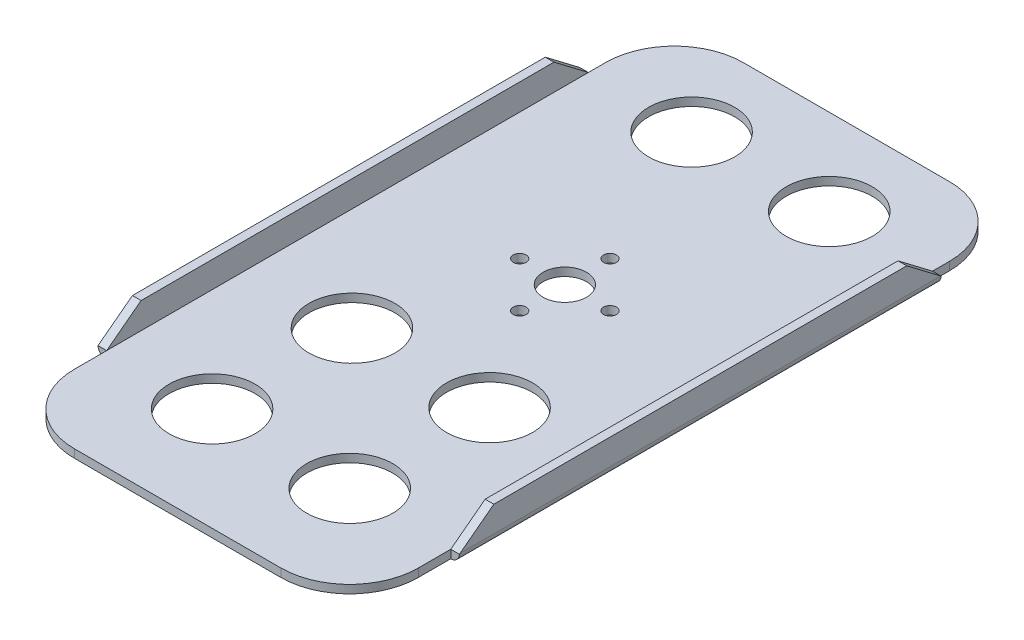
from build123d import *

# Parameters (mm, degrees)
SKETCH1_R               = 7.9375
SKETCH1_R_2             = 4.0005
SKETCH1_R_3             = 1.1938
EXTRUDE1_DEPTH          = 1.524
EXTRUDE2_DEPTH          = 6.35
CUT_EXTRUDE1_DEPTH      = 34.3502
CUT_EXTRUDE1_DEPTH_BACK = 34.3502
FILLET1_R               = 1.5875


with BuildPart() as part:
    # Sketch1 → Extrude1 (new body)
    with BuildSketch(Plane(origin=(0, 0, 0), x_dir=(1, 0, 0), z_dir=(0, 1, 0))):
        with BuildLine():
            Line((-31.75, -3.2004), (-31.75, -58.7756))
            ThreePointArc((-31.75, -58.7756), (-28.030256121, -67.755856121), (-19.05, -71.4756))
            Line((-19.05, -71.4756), (19.05, -71.4756))
            ThreePointArc((19.05, -71.4756), (28.030256121, -67.755856121), (31.75, -58.7756))
            Line((31.75, -58.7756), (31.75, -3.2004))
            Line((31.75, -3.2004), (31.75, 39.2684))
            ThreePointArc((31.75, 39.2684), (28.030256121, 48.248656121), (19.05, 51.9684))
            Line((19.05, 51.9684), (12.7, 51.9684))
            Line((12.7, 51.9684), (-12.7, 51.9684))
            Line((-12.7, 51.9684), (-19.05, 51.9684))
            ThreePointArc((-19.05, 51.9684), (-28.030256121, 48.248656121), (-31.75, 39.2684))
            Line((-31.75, 39.2684), (-31.75, -3.2004))
        make_face()
        with Locations(Location((-12.7, -52.4002, 0), (0, 0, 270))):  # turned: the seam where the file's is
            Circle(SKETCH1_R, mode=Mode.SUBTRACT)
        with Locations(Location((-12.7, 36.0934, 0), (0, 0, 270))):  # turned: the seam where the file's is
            Circle(SKETCH1_R, mode=Mode.SUBTRACT)
        with Locations(Location((12.7, -52.4002, 0), (0, 0, 270))):  # turned: the seam where the file's is
            Circle(SKETCH1_R, mode=Mode.SUBTRACT)
        with Locations(Location((12.7, -26.5938, 0), (0, 0, 270))):  # turned: the seam where the file's is
            Circle(SKETCH1_R, mode=Mode.SUBTRACT)
        with Locations(Location((12.7, 36.0934, 0), (0, 0, 270))):  # turned: the seam where the file's is
            Circle(SKETCH1_R, mode=Mode.SUBTRACT)
        with Locations(Location((0, 0, 0), (0, 0, 270))):  # turned: the seam where the file's is
            Circle(SKETCH1_R_2, mode=Mode.SUBTRACT)
        with Locations(Location((8.3312, 0, 0), (0, 0, 270))):  # turned: the seam where the file's is
            Circle(SKETCH1_R_3, mode=Mode.SUBTRACT)
        with Locations(Location((0, -8.3312, 0), (0, 0, 270))):  # turned: the seam where the file's is
            Circle(SKETCH1_R_3, mode=Mode.SUBTRACT)
        with Locations(Location((0, 8.3312, 0), (0, 0, 270))):  # turned: the seam where the file's is
            Circle(SKETCH1_R_3, mode=Mode.SUBTRACT)
        with Locations(Location((-8.3312, 0, 0), (0, 0, 270))):  # turned: the seam where the file's is
            Circle(SKETCH1_R_3, mode=Mode.SUBTRACT)
        with Locations(Location((-12.7, -26.5938, 0), (0, 0, 270))):  # turned: the seam where the file's is
            Circle(SKETCH1_R, mode=Mode.SUBTRACT)
    extrude(amount=EXTRUDE1_DEPTH)

    # Sketch1_3 → Extrude2 (add)
    with BuildSketch(Plane(origin=(0, 0, 0), x_dir=(1, 0, 0), z_dir=(0, 1, 0))):
        Polygon((31.75, 36.0934), (31.75, -3.2004), (31.75, -52.8066), (33.3502, -52.8066), (33.3502, 36.0934), align=None)
        Polygon((-33.3502, -52.8066), (-31.75, -52.8066), (-31.75, -3.2004), (-31.75, 36.0934), (-33.3502, 36.0934), align=None)
    extrude(amount=EXTRUDE2_DEPTH)

    # Sketch2 → Cut-Extrude1 (cut, two sides)
    with BuildSketch(Plane(origin=(0, 0, 0), x_dir=(0, 0, -1), z_dir=(1, 0, 0))) as cut_extrude1_sk:
        Polygon((-52.8066, 1.524), (-46.4566, 6.35), (-52.8066, 6.35), align=None)
        Polygon((36.0934, 6.35), (36.0934, 1.524), (29.7434, 6.35), align=None)
    extrude(amount=CUT_EXTRUDE1_DEPTH, mode=Mode.SUBTRACT)
    extrude(cut_extrude1_sk.sketch, amount=-CUT_EXTRUDE1_DEPTH_BACK, mode=Mode.SUBTRACT)

    # Fillet1
    fillet1_edges = [part.edges().sort_by_distance(p)[0] for p in [
        (33.3502, 0, 8.3566),
        (-33.3502, 0, 8.3566),
    ]]
    fillet(fillet1_edges, radius=FILLET1_R)


solid = part.part
